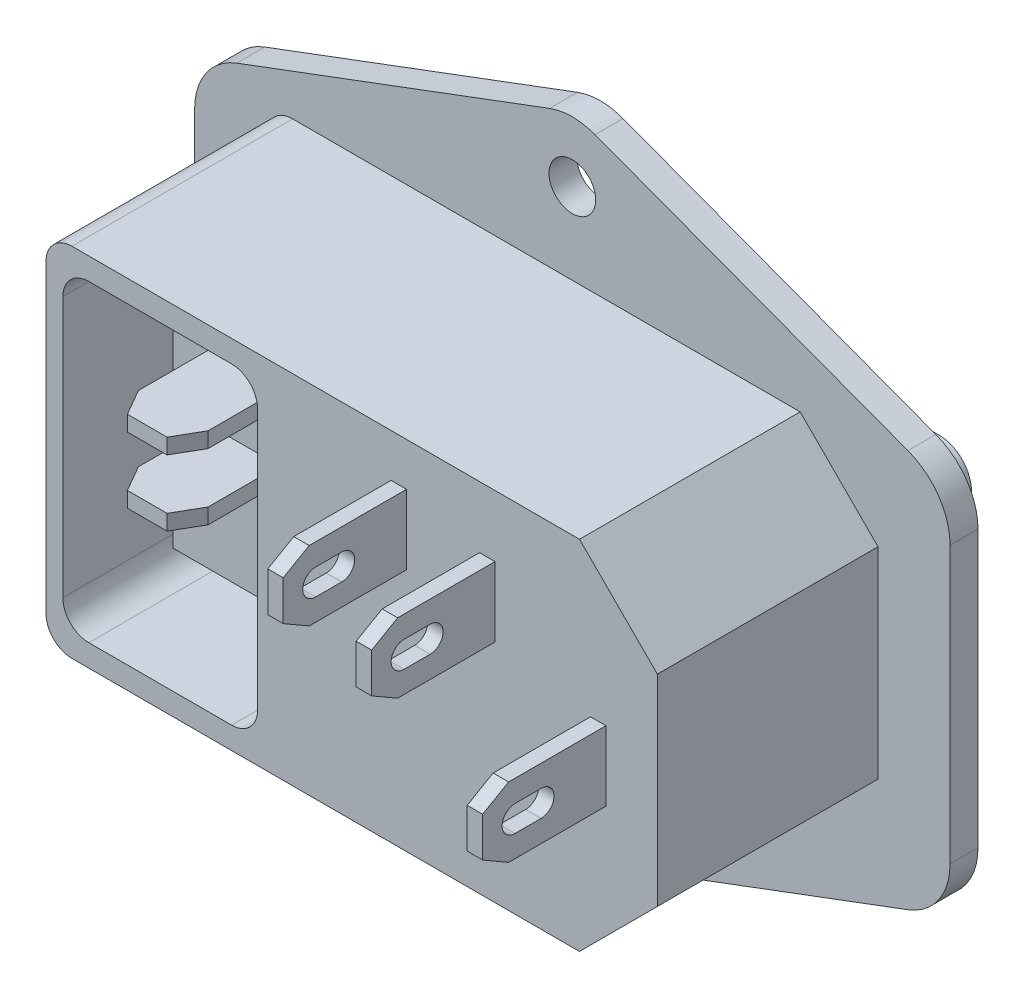
from build123d import *

# Parameters (mm, degrees)
SKETCH1_R              = 1.8
BOSS_EXTRUDE1_DEPTH    = 2.15
SKETCH2_W              = 47.1
SKETCH2_H              = 27.5
BOSS_EXTRUDE2_DEPTH    = 17
CHAMFER1_SIZE          = 6
FILLET1_R              = 2
FILLET2_R              = 5
SKETCH3_W              = 4.288476248
SKETCH3_H              = 1.692819572
SKETCH3_H_2            = 1.858600316
CUT_EXTRUDE1_DEPTH     = 17
BOSS_EXTRUDE3_DEPTH    = 1.4
SKETCH5_W              = 8.9
SKETCH5_H              = 24.9
SKETCH5_W_2            = 8.5
SKETCH5_H_2            = 24.5
CUT_EXTRUDE2_DEPTH     = 0.2
CUT_EXTRUDE3_START     = -20.55
CUT_EXTRUDE3_DEPTH     = 17.7
SKETCH8_W              = 11
SKETCH8_H              = 18
BOSS_EXTRUDE4_DEPTH    = 11.2
SKETCH9_W              = 5.366987426
SKETCH9_H              = 1.190055558
BOSS_EXTRUDE5_DEPTH    = 7.5
SKETCH10_W             = 15.35
SKETCH10_H             = 21.55
CUT_EXTRUDE4_DEPTH     = 1.5
SKETCH12_W             = 15.15
SKETCH12_H             = 21.35
SKETCH12_W_2           = 10.15
SKETCH12_H_2           = 16.35
BOSS_EXTRUDE6_DEPTH    = 1.5
BOSS_EXTRUDE7_DEPTH    = 5
SKETCH14_W             = 1.190055558
SKETCH14_H             = 5.366987427
BOSS_EXTRUDE8_DEPTH    = 9.5
CHAMFER3_SIZE          = 1
CHAMFER3_SIZE2         = 1.732050808
CHAMFER3_PART_2_SIZE   = 1
CHAMFER3_PART_2_SIZE2  = 1.732050808
CHAMFER3_PART_3_SIZE   = 1
CHAMFER3_PART_3_SIZE2  = 1.732050808
CHAMFER3_PART_4_SIZE   = 1
CHAMFER3_PART_4_SIZE2  = 1.732050808
CHAMFER2_SIZE          = 2
CHAMFER2_SIZE2         = 1.154700538
CHAMFER2_PART_2_SIZE   = 2
CHAMFER2_PART_2_SIZE2  = 1.154700538
CHAMFER2_PART_3_SIZE   = 2
CHAMFER2_PART_3_SIZE2  = 1.154700538
CHAMFER2_PART_4_SIZE   = 2
CHAMFER2_PART_4_SIZE2  = 1.154700538
CHAMFER2_PART_5_SIZE   = 2
CHAMFER2_PART_5_SIZE2  = 1.154700538
CHAMFER2_PART_6_SIZE   = 2
CHAMFER2_PART_6_SIZE2  = 1.154700538
CHAMFER2_PART_7_SIZE   = 2
CHAMFER2_PART_7_SIZE2  = 1.154700538
CHAMFER2_PART_8_SIZE   = 2
CHAMFER2_PART_8_SIZE2  = 1.154700538
CHAMFER2_PART_9_SIZE   = 2
CHAMFER2_PART_9_SIZE2  = 1.154700538
CHAMFER2_PART_10_SIZE  = 2
CHAMFER2_PART_10_SIZE2 = 1.154700538
CHAMFER2_PART_11_SIZE  = 2
CHAMFER2_PART_11_SIZE2 = 1.154700538
CHAMFER2_PART_12_SIZE  = 2
CHAMFER2_PART_12_SIZE2 = 1.154700538
CHAMFER2_PART_13_SIZE  = 2
CHAMFER2_PART_13_SIZE2 = 1.154700538
CHAMFER2_PART_14_SIZE  = 2
CHAMFER2_PART_14_SIZE2 = 1.154700538
CHAMFER2_PART_15_SIZE  = 2
CHAMFER2_PART_15_SIZE2 = 1.154700538
CHAMFER2_PART_16_SIZE  = 2
CHAMFER2_PART_16_SIZE2 = 1.154700538
CUT_EXTRUDE5_DEPTH     = 10
CUT_EXTRUDE6_DEPTH     = 2
CUT_EXTRUDE7_DEPTH     = 2


with BuildPart() as part:
    # Sketch1 → Boss-Extrude1 (new body)
    with BuildSketch(Plane.XY):
        Polygon((29.1, -14.1), (29.1, 14.1), (0, 25), (-29.1, 14.1), (-29.1, -14.1), (0, -25), align=None)
        with Locations((0, 20)):
            Circle(SKETCH1_R, mode=Mode.SUBTRACT)
        with Locations((0, -20)):
            Circle(SKETCH1_R, mode=Mode.SUBTRACT)
    extrude(amount=BOSS_EXTRUDE1_DEPTH)

    # Sketch2 → Boss-Extrude2 (add)
    with BuildSketch(Plane.XY.offset(2.15)):
        Rectangle(SKETCH2_W, SKETCH2_H)
    extrude(amount=BOSS_EXTRUDE2_DEPTH)

    # Chamfer1
    chamfer1_edges = [part.edges().sort_by_distance(p)[0] for p in [
        (23.55, -13.75, 10.65),
        (23.55, 13.75, 10.65),
    ]]
    chamfer(chamfer1_edges, length=CHAMFER1_SIZE)

    # Fillet1
    fillet1_edges = [part.edges().sort_by_distance(p)[0] for p in [
        (-23.55, 13.75, 10.65),
        (-23.55, -13.75, 10.65),
    ]]
    fillet(fillet1_edges, radius=FILLET1_R)

    # Fillet2
    fillet2_edges = [part.edges().sort_by_distance(p)[0] for p in [
        (-29.1, 14.1, 1.075),
        (0, 25, 1.075),
        (29.1, 14.1, 1.075),
        (29.1, -14.1, 1.075),
        (0, -25, 1.075),
        (-29.1, -14.1, 1.075),
    ]]
    fillet(fillet2_edges, radius=FILLET2_R)

    # Sketch3 → Cut-Extrude1 (cut)
    with BuildSketch(Plane(origin=(0, 0, 0), x_dir=(-1, 0, 0), z_dir=(0, 0, -1))):
        Polygon((-16.2, -12.1), (-6.2, -12.1), (-6.2, 12.1), (-16.2, 12.1), (-22.2, 6.1), (-22.2, -6.1), align=None)
        with Locations((-11.614985757, -7.531296487)):
            Rectangle(SKETCH3_W, SKETCH3_H, mode=Mode.SUBTRACT)
        with Locations((-17.821990853, 0)):
            Rectangle(SKETCH3_W, SKETCH3_H_2, mode=Mode.SUBTRACT)
        with Locations((-11.614985757, 7.531296487)):
            Rectangle(SKETCH3_W, SKETCH3_H, mode=Mode.SUBTRACT)
    extrude(amount=-CUT_EXTRUDE1_DEPTH, mode=Mode.SUBTRACT)

    # Sketch4 → Boss-Extrude3 (add)
    with BuildSketch(Plane(origin=(0, 0, 0), x_dir=(-1, 0, 0), z_dir=(0, 0, -1))):
        with BuildLine():
            Line((-24.7, -14), (24.7, -14))
            ThreePointArc((24.7, -14), (26.467766953, -13.267766953), (27.2, -11.5))
            Line((27.2, -11.5), (27.2, 11.5))
            ThreePointArc((27.2, 11.5), (26.467766953, 13.267766953), (24.7, 14))
            Line((24.7, 14), (-24.7, 14))
            ThreePointArc((-24.7, 14), (-26.467766953, 13.267766953), (-27.2, 11.5))
            Line((-27.2, 11.5), (-27.2, -11.5))
            ThreePointArc((-27.2, -11.5), (-26.467766953, -13.267766953), (-24.7, -14))
        make_face()
        Polygon((-6.2, -12.1), (-6.2, 12.1), (-16.2, 12.1), (-22.2, 6.1), (-22.2, -6.1), (-16.2, -12.1), align=None, mode=Mode.SUBTRACT)
    extrude(amount=BOSS_EXTRUDE3_DEPTH)

    # Sketch5 → Cut-Extrude2 (cut)
    with BuildSketch(Plane(origin=(0, 0, -1.4), x_dir=(-1, 0, 0), z_dir=(0, 0, -1))):
        with Locations((1.15, 0)):
            Rectangle(SKETCH5_W, SKETCH5_H)
        with Locations((1.15, 0)):
            Rectangle(SKETCH5_W_2, SKETCH5_H_2, mode=Mode.SUBTRACT)
        Polygon((-1.689278438, -9.440617978), (4.448211796, -9.440617978), (4.448211796, -4.751257717), (2.988338361, -4.751257717), (2.988338361, 4.751257717), (4.448211796, 4.751257717), (4.448211796, 9.440617978), (-1.689278438, 9.440617978), (-1.689278438, 4.751257717), (-0.229405004, 4.751257717), (-0.229405004, -4.751257717), (-1.689278438, -4.751257717), align=None)
        Polygon((2.688338361, 5.051257717), (4.148211796, 5.051257717), (4.148211796, 9.140617978), (-1.389278438, 9.140617978), (-1.389278438, 5.051257717), (0.070594996, 5.051257717), (0.070594996, -5.051257717), (-1.389278438, -5.051257717), (-1.389278438, -9.140617978), (4.148211796, -9.140617978), (4.148211796, -5.051257717), (2.688338361, -5.051257717), align=None, mode=Mode.SUBTRACT)
    extrude(amount=-CUT_EXTRUDE2_DEPTH, mode=Mode.SUBTRACT)

    # Sketch6 → Cut-Extrude3 (cut)
    with BuildSketch(Plane(origin=(0, 0, -1.4), x_dir=(-1, 0, 0), z_dir=(0, 0, -1)).offset(CUT_EXTRUDE3_START)):
        with BuildLine():
            Line((9.25, -12.05), (20.25, -12.05))
            ThreePointArc((20.25, -12.05), (21.664213562, -11.464213562), (22.25, -10.05))
            Line((22.25, -10.05), (22.25, 10.05))
            ThreePointArc((22.25, 10.05), (21.664213562, 11.464213562), (20.25, 12.05))
            Line((20.25, 12.05), (9.25, 12.05))
            ThreePointArc((9.25, 12.05), (7.835786438, 11.464213562), (7.25, 10.05))
            Line((7.25, 10.05), (7.25, -10.05))
            ThreePointArc((7.25, -10.05), (7.835786438, -11.464213562), (9.25, -12.05))
        make_face()
    extrude(amount=CUT_EXTRUDE3_DEPTH, mode=Mode.SUBTRACT)

    # Sketch8 → Boss-Extrude4 (add)
    with BuildSketch(Plane.XY.offset(1.45)):
        with Locations((-14.75, 0)):
            Rectangle(SKETCH8_W, SKETCH8_H)
    extrude(amount=BOSS_EXTRUDE4_DEPTH)

    # Sketch9 → Boss-Extrude5 (add)
    with BuildSketch(Plane.XY.offset(12.65)):
        with Locations((-14.75, 5.083540573)):
            Rectangle(SKETCH9_W, SKETCH9_H)
        with Locations((-14.75, 0)):
            Rectangle(SKETCH9_W, SKETCH9_H)
    extrude(amount=BOSS_EXTRUDE5_DEPTH)

    # Sketch10 → Cut-Extrude4 (cut)
    with BuildSketch(Plane(origin=(0, 0, -1.4), x_dir=(-1, 0, 0), z_dir=(0, 0, -1))):
        with Locations((14.75, 0)):
            Rectangle(SKETCH10_W, SKETCH10_H)
    extrude(amount=-CUT_EXTRUDE4_DEPTH, mode=Mode.SUBTRACT)

    # Sketch12 → Boss-Extrude6 (add)
    with BuildSketch(Plane(origin=(0, 0, 0.1), x_dir=(-1, 0, 0), z_dir=(0, 0, -1))):
        with Locations((14.75, 0)):
            Rectangle(SKETCH12_W, SKETCH12_H)
        with Locations((14.75, 0)):
            Rectangle(SKETCH12_W_2, SKETCH12_H_2, mode=Mode.SUBTRACT)
    extrude(amount=BOSS_EXTRUDE6_DEPTH)

    # Sketch13 → Boss-Extrude7 (add, symmetric)
    with BuildSketch(Plane(origin=(-14.75, 0, 0), x_dir=(0, 0, -1), z_dir=(1, 0, 0))):
        with BuildLine():
            Line((-0.1, -7.425430553), (-0.1, 7.592832676))
            add(Edge.make_bspline(
                [(-0.1, 7.592832676), (3.659456074, 7.436561647), (6.740460895, 5.170946804)],
                knots=[0, 0, 0, 1, 1, 1], degree=2))
            add(Edge.make_bspline(
                [(1.4, -7.425430553), (1.349217411, 0.057710123), (6.740460895, 5.170946804)],
                knots=[0, 0, 0, 1, 1, 1], degree=2))
            Line((1.4, -7.425430553), (-0.1, -7.425430553))
        make_face()
    extrude(amount=BOSS_EXTRUDE7_DEPTH, both=True)

    # Sketch14 → Boss-Extrude8 (add)
    with BuildSketch(Plane.XY.offset(19.15)):
        with Locations((3.631590691, 7.738834836)):
            Rectangle(SKETCH14_W, SKETCH14_H)
        with Locations((10.444142343, 6.321458318)):
            Rectangle(SKETCH14_W, SKETCH14_H)
        with Locations((18.994123277, -0.353927865)):
            Rectangle(SKETCH14_W, SKETCH14_H)
    extrude(amount=BOSS_EXTRUDE8_DEPTH)

    # Chamfer3
    chamfer3_edges = [part.edges().sort_by_distance(p)[0] for p in [
        (-22.325, 0, -1.4),
    ]]
    chamfer3_side = [part.faces().sort_by_distance(p)[0] for p in [
        (-22.325, 0, -0.65),
    ]]
    chamfer(chamfer3_edges, length=CHAMFER3_SIZE, length2=CHAMFER3_SIZE2, reference=chamfer3_side[0])

    # Chamfer3 part 2
    chamfer3_part_2_edges = [part.edges().sort_by_distance(p)[0] for p in [
        (-14.75, 10.675, -1.4),
    ]]
    chamfer3_part_2_side = [part.faces().sort_by_distance(p)[0] for p in [
        (-14.75, 10.675, -0.65),
    ]]
    chamfer(chamfer3_part_2_edges, length=CHAMFER3_PART_2_SIZE, length2=CHAMFER3_PART_2_SIZE2, reference=chamfer3_part_2_side[0])

    # Chamfer3 part 3
    chamfer3_part_3_edges = [part.edges().sort_by_distance(p)[0] for p in [
        (-7.175, 0, -1.4),
    ]]
    chamfer3_part_3_side = [part.faces().sort_by_distance(p)[0] for p in [
        (-7.175, 0, -0.65),
    ]]
    chamfer(chamfer3_part_3_edges, length=CHAMFER3_PART_3_SIZE, length2=CHAMFER3_PART_3_SIZE2, reference=chamfer3_part_3_side[0])

    # Chamfer3 part 4
    chamfer3_part_4_edges = [part.edges().sort_by_distance(p)[0] for p in [
        (-14.75, -10.675, -1.4),
    ]]
    chamfer3_part_4_side = [part.faces().sort_by_distance(p)[0] for p in [
        (-14.75, -10.675, -0.65),
    ]]
    chamfer(chamfer3_part_4_edges, length=CHAMFER3_PART_4_SIZE, length2=CHAMFER3_PART_4_SIZE2, reference=chamfer3_part_4_side[0])

    # Chamfer2
    chamfer2_edges = [part.edges().sort_by_distance(p)[0] for p in [
        (15.677752729, 0, 0),
    ]]
    chamfer2_side = [part.faces().sort_by_distance(p)[0] for p in [
        (15.677752729, 0, 8.5),
    ]]
    chamfer(chamfer2_edges, length=CHAMFER2_SIZE, length2=CHAMFER2_SIZE2, reference=chamfer2_side[0])

    # Chamfer2 part 2
    chamfer2_part_2_edges = [part.edges().sort_by_distance(p)[0] for p in [
        (19.966228977, 0, 0),
    ]]
    chamfer2_part_2_side = [part.faces().sort_by_distance(p)[0] for p in [
        (19.966228977, 0, 8.5),
    ]]
    chamfer(chamfer2_part_2_edges, length=CHAMFER2_PART_2_SIZE, length2=CHAMFER2_PART_2_SIZE2, reference=chamfer2_part_2_side[0])

    # Chamfer2 part 3
    chamfer2_part_3_edges = [part.edges().sort_by_distance(p)[0] for p in [
        (9.470747633, 7.531296487, 0),
    ]]
    chamfer2_part_3_side = [part.faces().sort_by_distance(p)[0] for p in [
        (9.470747633, 7.531296487, 8.5),
    ]]
    chamfer(chamfer2_part_3_edges, length=CHAMFER2_PART_3_SIZE, length2=CHAMFER2_PART_3_SIZE2, reference=chamfer2_part_3_side[0])

    # Chamfer2 part 4
    chamfer2_part_4_edges = [part.edges().sort_by_distance(p)[0] for p in [
        (13.759223881, 7.531296487, 0),
    ]]
    chamfer2_part_4_side = [part.faces().sort_by_distance(p)[0] for p in [
        (13.759223881, 7.531296487, 8.5),
    ]]
    chamfer(chamfer2_part_4_edges, length=CHAMFER2_PART_4_SIZE, length2=CHAMFER2_PART_4_SIZE2, reference=chamfer2_part_4_side[0])

    # Chamfer2 part 5
    chamfer2_part_5_edges = [part.edges().sort_by_distance(p)[0] for p in [
        (13.759223881, -7.531296487, 0),
    ]]
    chamfer2_part_5_side = [part.faces().sort_by_distance(p)[0] for p in [
        (13.759223881, -7.531296487, 8.5),
    ]]
    chamfer(chamfer2_part_5_edges, length=CHAMFER2_PART_5_SIZE, length2=CHAMFER2_PART_5_SIZE2, reference=chamfer2_part_5_side[0])

    # Chamfer2 part 6
    chamfer2_part_6_edges = [part.edges().sort_by_distance(p)[0] for p in [
        (9.470747633, -7.531296487, 0),
    ]]
    chamfer2_part_6_side = [part.faces().sort_by_distance(p)[0] for p in [
        (9.470747633, -7.531296487, 8.5),
    ]]
    chamfer(chamfer2_part_6_edges, length=CHAMFER2_PART_6_SIZE, length2=CHAMFER2_PART_6_SIZE2, reference=chamfer2_part_6_side[0])

    # Chamfer2 part 7
    chamfer2_part_7_edges = [part.edges().sort_by_distance(p)[0] for p in [
        (-12.066506287, 5.083540573, 20.15),
    ]]
    chamfer2_part_7_side = [part.faces().sort_by_distance(p)[0] for p in [
        (-12.066506287, 5.083540573, 16.4),
    ]]
    chamfer(chamfer2_part_7_edges, length=CHAMFER2_PART_7_SIZE, length2=CHAMFER2_PART_7_SIZE2, reference=chamfer2_part_7_side[0])

    # Chamfer2 part 8
    chamfer2_part_8_edges = [part.edges().sort_by_distance(p)[0] for p in [
        (-17.433493713, 5.083540573, 20.15),
    ]]
    chamfer2_part_8_side = [part.faces().sort_by_distance(p)[0] for p in [
        (-17.433493713, 5.083540573, 16.4),
    ]]
    chamfer(chamfer2_part_8_edges, length=CHAMFER2_PART_8_SIZE, length2=CHAMFER2_PART_8_SIZE2, reference=chamfer2_part_8_side[0])

    # Chamfer2 part 9
    chamfer2_part_9_edges = [part.edges().sort_by_distance(p)[0] for p in [
        (-12.066506287, 0, 20.15),
    ]]
    chamfer2_part_9_side = [part.faces().sort_by_distance(p)[0] for p in [
        (-12.066506287, 0, 16.4),
    ]]
    chamfer(chamfer2_part_9_edges, length=CHAMFER2_PART_9_SIZE, length2=CHAMFER2_PART_9_SIZE2, reference=chamfer2_part_9_side[0])

    # Chamfer2 part 10
    chamfer2_part_10_edges = [part.edges().sort_by_distance(p)[0] for p in [
        (-17.433493713, 0, 20.15),
    ]]
    chamfer2_part_10_side = [part.faces().sort_by_distance(p)[0] for p in [
        (-17.433493713, 0, 16.4),
    ]]
    chamfer(chamfer2_part_10_edges, length=CHAMFER2_PART_10_SIZE, length2=CHAMFER2_PART_10_SIZE2, reference=chamfer2_part_10_side[0])

    # Chamfer2 part 11
    chamfer2_part_11_edges = [part.edges().sort_by_distance(p)[0] for p in [
        (3.631590691, 10.422328549, 28.65),
    ]]
    chamfer2_part_11_side = [part.faces().sort_by_distance(p)[0] for p in [
        (3.631590691, 10.422328549, 23.9),
    ]]
    chamfer(chamfer2_part_11_edges, length=CHAMFER2_PART_11_SIZE, length2=CHAMFER2_PART_11_SIZE2, reference=chamfer2_part_11_side[0])

    # Chamfer2 part 12
    chamfer2_part_12_edges = [part.edges().sort_by_distance(p)[0] for p in [
        (3.631590691, 5.055341122, 28.65),
    ]]
    chamfer2_part_12_side = [part.faces().sort_by_distance(p)[0] for p in [
        (3.631590691, 5.055341122, 23.9),
    ]]
    chamfer(chamfer2_part_12_edges, length=CHAMFER2_PART_12_SIZE, length2=CHAMFER2_PART_12_SIZE2, reference=chamfer2_part_12_side[0])

    # Chamfer2 part 13
    chamfer2_part_13_edges = [part.edges().sort_by_distance(p)[0] for p in [
        (10.444142343, 3.637964604, 28.65),
    ]]
    chamfer2_part_13_side = [part.faces().sort_by_distance(p)[0] for p in [
        (10.444142343, 3.637964604, 23.9),
    ]]
    chamfer(chamfer2_part_13_edges, length=CHAMFER2_PART_13_SIZE, length2=CHAMFER2_PART_13_SIZE2, reference=chamfer2_part_13_side[0])

    # Chamfer2 part 14
    chamfer2_part_14_edges = [part.edges().sort_by_distance(p)[0] for p in [
        (10.444142343, 9.004952031, 28.65),
    ]]
    chamfer2_part_14_side = [part.faces().sort_by_distance(p)[0] for p in [
        (10.444142343, 9.004952031, 23.9),
    ]]
    chamfer(chamfer2_part_14_edges, length=CHAMFER2_PART_14_SIZE, length2=CHAMFER2_PART_14_SIZE2, reference=chamfer2_part_14_side[0])

    # Chamfer2 part 15
    chamfer2_part_15_edges = [part.edges().sort_by_distance(p)[0] for p in [
        (18.994123277, -3.037421579, 28.65),
    ]]
    chamfer2_part_15_side = [part.faces().sort_by_distance(p)[0] for p in [
        (18.994123277, -3.037421579, 23.9),
    ]]
    chamfer(chamfer2_part_15_edges, length=CHAMFER2_PART_15_SIZE, length2=CHAMFER2_PART_15_SIZE2, reference=chamfer2_part_15_side[0])

    # Chamfer2 part 16
    chamfer2_part_16_edges = [part.edges().sort_by_distance(p)[0] for p in [
        (18.994123277, 2.329565848, 28.65),
    ]]
    chamfer2_part_16_side = [part.faces().sort_by_distance(p)[0] for p in [
        (18.994123277, 2.329565848, 23.9),
    ]]
    chamfer(chamfer2_part_16_edges, length=CHAMFER2_PART_16_SIZE, length2=CHAMFER2_PART_16_SIZE2, reference=chamfer2_part_16_side[0])

    # Sketch15 → Cut-Extrude5 (cut)
    with BuildSketch(Plane(origin=(19.589151056, 0, 0), x_dir=(0, 0, -1), z_dir=(1, 0, 0))):
        with BuildLine():
            Line((-26.15, 0.646072134), (-24.15, 0.646072134))
            ThreePointArc((-24.15, 0.646072134), (-23.15, -0.353927866), (-24.15, -1.353927866))
            Line((-24.15, -1.353927866), (-26.15, -1.353927866))
            ThreePointArc((-26.15, -1.353927866), (-27.15, -0.353927866), (-26.15, 0.646072134))
        make_face()
    extrude(amount=-CUT_EXTRUDE5_DEPTH, mode=Mode.SUBTRACT)

    # Sketch16 → Cut-Extrude6 (cut)
    with BuildSketch(Plane(origin=(11.039170122, 0, 0), x_dir=(0, 0, -1), z_dir=(1, 0, 0))):
        with BuildLine():
            Line((-24.15, 5.321458318), (-26.15, 5.321458318))
            ThreePointArc((-26.15, 5.321458318), (-27.15, 6.321458318), (-26.15, 7.321458318))
            Line((-26.15, 7.321458318), (-24.15, 7.321458318))
            ThreePointArc((-24.15, 7.321458318), (-23.15, 6.321458318), (-24.15, 5.321458318))
        make_face()
    extrude(amount=-CUT_EXTRUDE6_DEPTH, mode=Mode.SUBTRACT)

    # Sketch17 → Cut-Extrude7 (cut)
    with BuildSketch(Plane.ZY.offset(-3.036562912)):
        with BuildLine():
            Line((24.15, 8.738799039), (26.15, 8.738799039))
            ThreePointArc((26.15, 8.738799039), (27.149964203, 7.738834836), (26.15, 6.738870633))
            Line((26.15, 6.738870633), (24.15, 6.738870633))
            ThreePointArc((24.15, 6.738870633), (23.150035797, 7.738834836), (24.15, 8.738799039))
        make_face()
    extrude(amount=-CUT_EXTRUDE7_DEPTH, mode=Mode.SUBTRACT)


solid = part.part
